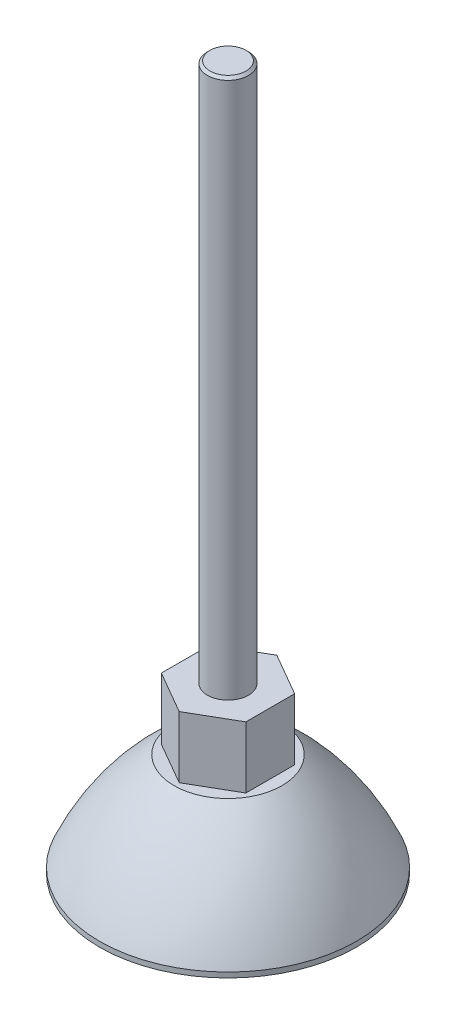
from build123d import *

# Parameters (mm, degrees)
CHAMFER_1_SIZE      = 0.5
SKETCH_3_R          = 25
CUT_EXTRUDE_1_DEPTH = 12


with BuildPart() as part:
    # Эскиз1 → Повернуть1 (revolve)
    with BuildSketch(Plane.XY, mode=Mode.PRIVATE) as revolve_1_sk:
        with BuildLine():
            Line((0, 137), (-4, 137))
            Line((-4, 137), (-4, 32))
            Line((-4, 32), (-9.5, 32))
            Line((-9.5, 32), (-9.5, 20))
            Line((-9.5, 20), (-10.5, 20))
            ThreePointArc((-10.5, 20), (-18.901983424, 11.379145244), (-25, 1))
            Line((-25, 1), (-25, 0))
            Line((-25, 0), (0, 0))
            Line((0, 0), (0, 137))
        make_face()
    revolve(revolve_1_sk.sketch.rotate(Axis((0, 0, 0), (0, 1, 0)), 180), axis=Axis((0, 0, 0), (0, 1, 0)))  # turned: the seam where the file's is

    # Фаска1
    chamfer_1_edges = [part.edges().sort_by_distance(p)[0] for p in [
        (-4, 137, 0),
    ]]
    chamfer(chamfer_1_edges, length=CHAMFER_1_SIZE)

    # Эскиз3 → Вырез-Вытянуть1 (cut)
    with BuildSketch(Plane(origin=(0, 32, 0), x_dir=(1, 0, 0), z_dir=(0, 1, 0))):
        Circle(SKETCH_3_R)
        Polygon((0, 9.5), (-8.227241336, 4.75), (-8.227241336, -4.75), (0, -9.5), (8.227241336, -4.75), (8.227241336, 4.75), align=None, mode=Mode.SUBTRACT)
    extrude(amount=-CUT_EXTRUDE_1_DEPTH, mode=Mode.SUBTRACT)


solid = part.part
